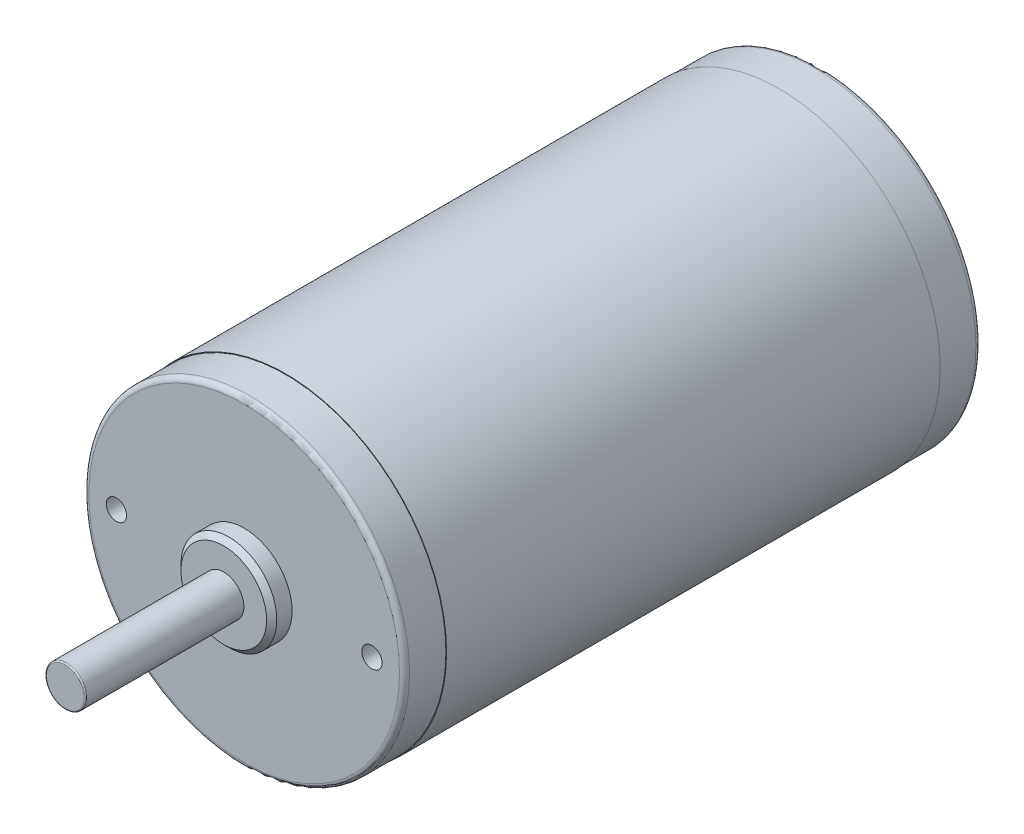
from build123d import *

# Parameters (mm, degrees)
SKETCH1_W           = 32.004
SKETCH1_H           = 98.1456
SKETCH2_R           = 31.877
BOSS_EXTRUDE1_DEPTH = 8.2296
SKETCH5_R           = 9.525
BOSS_EXTRUDE2_DEPTH = 4.572
SKETCH6_R           = 4
BOSS_EXTRUDE3_DEPTH = 31.5
SKETCH8_R           = 31.877
BOSS_EXTRUDE4_DEPTH = 8.2296
SKETCH9_R           = 15.0368
BOSS_EXTRUDE5_DEPTH = 4.7625
HOLE2_D             = 4.0386
HOLE2_DEPTH         = 13.6144
HOLE2_TIP           = 1.213317848
HOLE3_D             = 4.0386
HOLE3_DEPTH         = 13.6144
HOLE3_TIP           = 1.213317848
CHAMFER1_SIZE2      = 1.016
CHAMFER1_SIZE       = 1.015999998
FILLET1_R           = 0.254
FILLET2_R           = 1
FILLET3_R           = 1
FILLET4_R           = 1


with BuildPart() as part:
    # Sketch1 → Revolve1 (revolve)
    with BuildSketch(Plane.XZ.offset(-109.2962)):
        with Locations((51.562, -38.2524)):
            Rectangle(SKETCH1_W, SKETCH1_H)
    revolve(axis=Axis((35.56, 109.2962, 10.8204), (0, 0, -1)))

    # Sketch2 → Boss-Extrude1 (add)
    with BuildSketch(Plane.XY.offset(10.8204)):
        with Locations((35.56, 109.2962)):
            Circle(SKETCH2_R)
    extrude(amount=BOSS_EXTRUDE1_DEPTH)

    # Sketch5 → Boss-Extrude2 (add)
    with BuildSketch(Plane(origin=(0, 0, 18.542), x_dir=(-1, 0, 0), z_dir=(0, 0, -1))):
        with Locations((-35.56, 109.2962)):
            Circle(SKETCH5_R)
    extrude(amount=-BOSS_EXTRUDE2_DEPTH)

    # Sketch6 → Boss-Extrude3 (add)
    with BuildSketch(Plane.XY.offset(23.114)):
        with Locations((35.56, 109.2962)):
            Circle(SKETCH6_R)
    extrude(amount=BOSS_EXTRUDE3_DEPTH)

    # Sketch8 → Boss-Extrude4 (add)
    with BuildSketch(Plane(origin=(0, 0, -87.3252), x_dir=(-1, 0, 0), z_dir=(0, 0, -1))):
        with Locations((-35.56, 109.2962)):
            Circle(SKETCH8_R)
    extrude(amount=BOSS_EXTRUDE4_DEPTH)

    # Sketch9 → Boss-Extrude5 (add)
    with BuildSketch(Plane(origin=(0, 0, -95.5548), x_dir=(-1, 0, 0), z_dir=(0, 0, -1))):
        with Locations((-35.56, 109.2962)):
            Circle(SKETCH9_R)
    extrude(amount=BOSS_EXTRUDE5_DEPTH)

    # Hole2
    with Locations(Plane.XY.offset(19.05)):
        with Locations((60.96, 109.2962)):
            Hole(HOLE2_D / 2, depth=HOLE2_DEPTH)
            with Locations((0, 0, -(HOLE2_DEPTH + HOLE2_TIP / 2))):  # 118° drill point
                Cone(0, HOLE2_D / 2, HOLE2_TIP, mode=Mode.SUBTRACT)

    # Hole3
    with Locations(Plane.XY.offset(19.05)):
        with Locations((10.16, 109.2962)):
            Hole(HOLE3_D / 2, depth=HOLE3_DEPTH)
            with Locations((0, 0, -(HOLE3_DEPTH + HOLE3_TIP / 2))):  # 118° drill point
                Cone(0, HOLE3_D / 2, HOLE3_TIP, mode=Mode.SUBTRACT)

    # Chamfer1
    chamfer1_edges = [part.edges().sort_by_distance(p)[0] for p in [
        (45.085, 109.2962, 23.114),
    ]]
    chamfer(chamfer1_edges, length=CHAMFER1_SIZE, length2=CHAMFER1_SIZE2)

    # Fillet1
    fillet1_edges = [part.edges().sort_by_distance(p)[0] for p in [
        (31.56, 109.2962, 54.614),
    ]]
    fillet(fillet1_edges, radius=FILLET1_R)

    # Fillet2
    fillet2_edges = [part.edges().sort_by_distance(p)[0] for p in [
        (67.437, 109.2962, -95.5548),
    ]]
    fillet(fillet2_edges, radius=FILLET2_R)

    # Fillet3
    fillet3_edges = [part.edges().sort_by_distance(p)[0] for p in [
        (3.683, 109.2962, 19.05),
    ]]
    fillet(fillet3_edges, radius=FILLET3_R)

    # Fillet4
    fillet4_edges = [part.edges().sort_by_distance(p)[0] for p in [
        (50.5968, 109.2962, -100.3173),
    ]]
    fillet(fillet4_edges, radius=FILLET4_R)


solid = part.part
